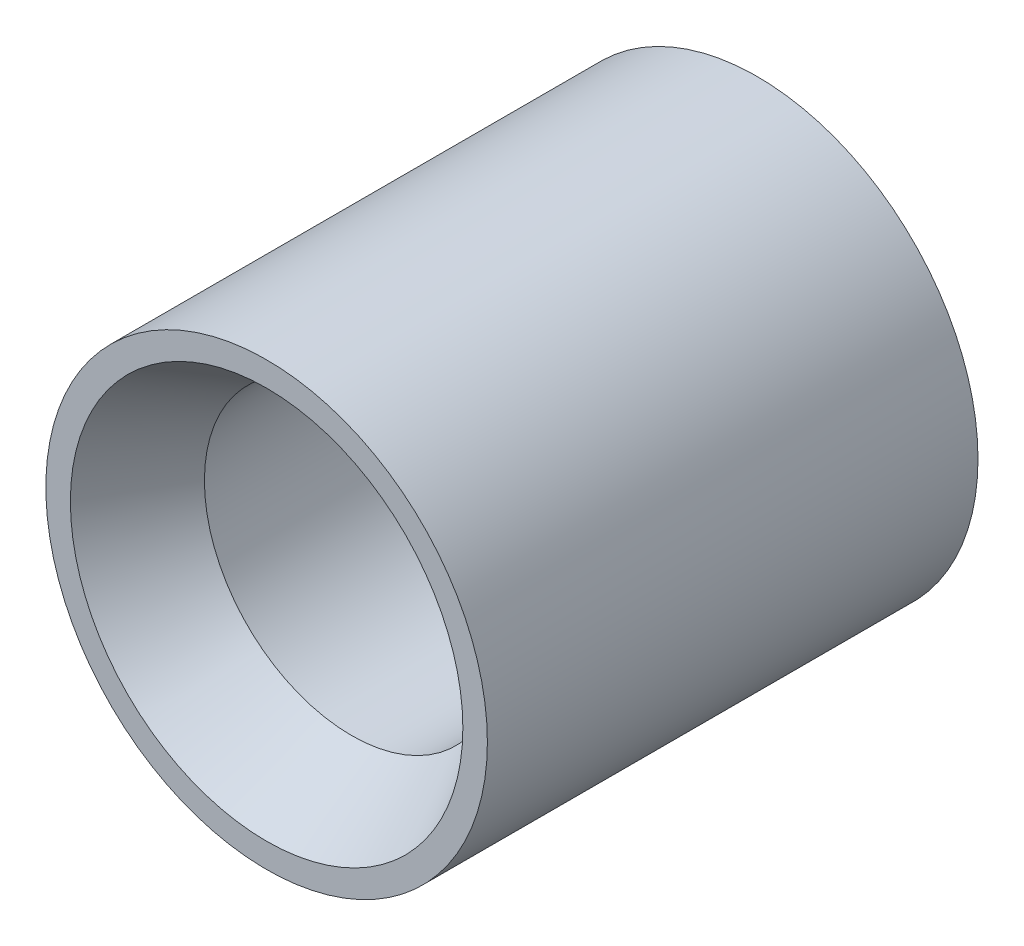
from build123d import *

# Parameters (mm, degrees)
SKETCH1_R           = 4.5
SKETCH1_R_2         = 3
BOSS_EXTRUDE1_DEPTH = 10


with BuildPart() as part:
    # Sketch1 → Boss-Extrude1 (new body)
    with BuildSketch(Plane.XY):
        Circle(SKETCH1_R)
        Circle(SKETCH1_R_2, mode=Mode.SUBTRACT)
    extrude(amount=BOSS_EXTRUDE1_DEPTH)

    # Sketch2 → Cut-Revolve1 (revolve, cut)
    with BuildSketch(Plane(origin=(0, 0, 0), x_dir=(1, 0, 0), z_dir=(0, 1, 0))):
        Polygon((-4, -10), (0, -3.07179677), (0, -10), align=None)
    revolve(axis=Axis((0, 0, 0), (0, 0, 1)), mode=Mode.SUBTRACT)


solid = part.part
